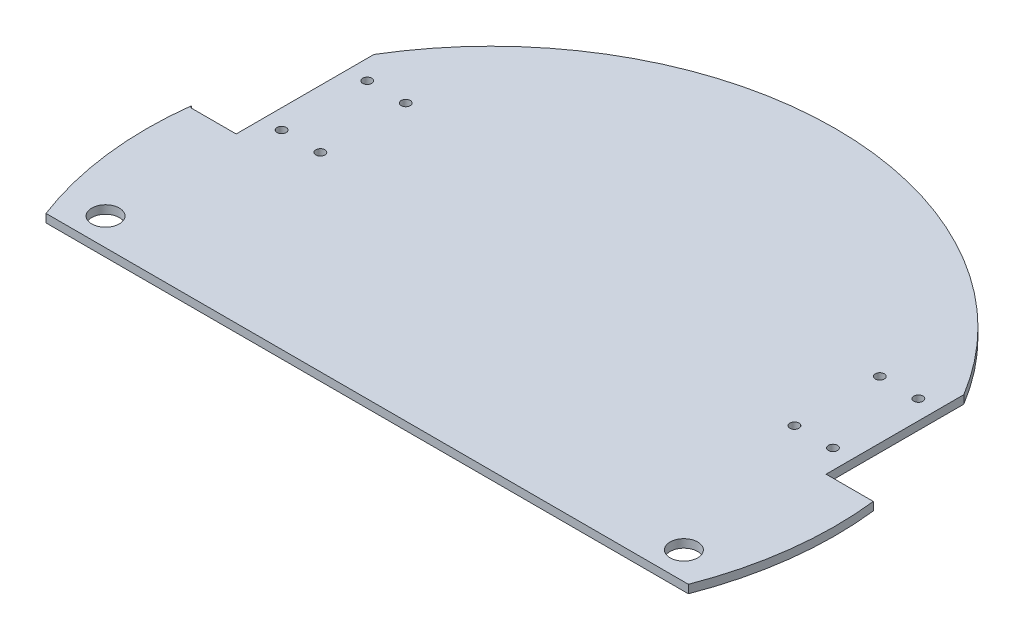
from build123d import *

# Parameters (mm, degrees)
SKETCH2_R           = 125
BOSS_EXTRUDE1_DEPTH = 3
CUT_EXTRUDE1_DEPTH  = 3
SKETCH4_R           = 1.65
SKETCH4_R_2         = 5
CUT_EXTRUDE2_DEPTH  = 10


with BuildPart() as part:
    # Sketch2 → Boss-Extrude1 (new body)
    with BuildSketch(Plane(origin=(0, 0, 0), x_dir=(1, 0, 0), z_dir=(0, 1, 0))):
        with Locations((-17.80765369, -0.854894607)):
            Circle(SKETCH2_R)
    extrude(amount=BOSS_EXTRUDE1_DEPTH)

    # Sketch3 → Cut-Extrude1 (cut)
    with BuildSketch(Plane.XZ):
        Polygon((-735.289651923, 45.854894607), (-134.426691587, 45.854894607), (98.811384207, 45.854894607), (699.674344543, 45.854894607), (699.674344543, 1247.580815278), (-735.289651923, 1247.580815278), align=None)
    extrude(amount=-CUT_EXTRUDE1_DEPTH, mode=Mode.SUBTRACT)

    # Sketch4 → Cut-Extrude2 (cut)
    with BuildSketch(Plane(origin=(0, 0, 0), x_dir=(-1, 0, 0), z_dir=(0, -1, 0))):
        with Locations((117.80765369, 54.145105393)):
            Circle(SKETCH4_R)
        with Locations((117.881226527, 23.145192699)):
            Circle(SKETCH4_R)
        with Locations((103.80765369, 54.145105393)):
            Circle(SKETCH4_R)
        with Locations((103.80765369, 23.145105393)):
            Circle(SKETCH4_R)
        with Locations((-68.19234631, 54.267083079)):
            Circle(SKETCH4_R)
        with Locations((-82.19234631, 54.267083079)):
            Circle(SKETCH4_R)
        with Locations((-82.19234631, 23.267083079)):
            Circle(SKETCH4_R)
        with Locations((-68.19234631, 23.267083079)):
            Circle(SKETCH4_R)
        with Locations((122.80765369, -35.854894607)):
            Circle(SKETCH4_R_2)
        with Locations((-87.19234631, -35.854894607)):
            Circle(SKETCH4_R_2)
        Polygon((124.881226527, 63.645105393), (124.881226527, 13.645105393), (141.357501756, 13.645105393), (159.377606719, 40.481299306), align=None)
        Polygon((-89.19234631, 63.767083079), (-89.19234631, 13.767083079), (-106.334191667, 13.767083079), (-114.079843912, 54.596315864), align=None)
    extrude(amount=-CUT_EXTRUDE2_DEPTH, mode=Mode.SUBTRACT)


solid = part.part
